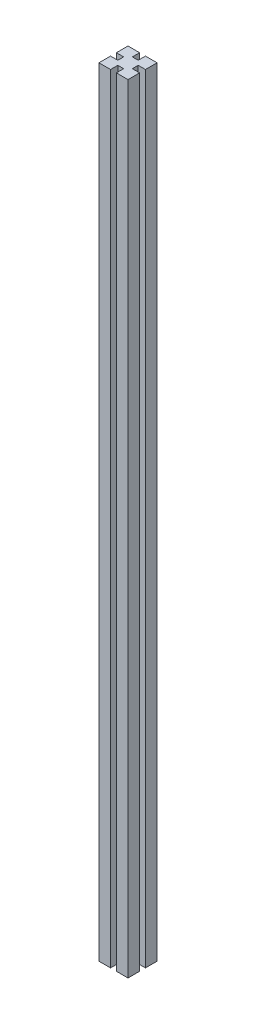
from build123d import *

# Parameters (mm, degrees)
BOSS_EXTRUDE1_DEPTH = 1338
BOSS_EXTRUDE2_DEPTH = 10


with BuildPart() as part:
    # Sketch1 → Boss-Extrude1 (new body)
    with BuildSketch(Plane(origin=(0, 0, 0), x_dir=(1, 0, 0), z_dir=(0, 1, 0))):
        Polygon((-25, 25), (-5, 25), (-5, 12.5), (5, 12.5), (5, 25), (25, 25), (25, 5), (12.5, 5), (12.5, -5), (25, -5), (25, -25), (5, -25), (5, -12.5), (-5, -12.5), (-5, -25), (-25, -25), (-25, -5), (-12.5, -5), (-12.5, 5), (-25, 5), align=None)
    extrude(amount=BOSS_EXTRUDE1_DEPTH)

    # Sketch1_2 → Boss-Extrude2 (add)
    with BuildSketch(Plane(origin=(0, 0, 0), x_dir=(1, 0, 0), z_dir=(0, 1, 0))):
        Polygon((-25, 25), (-5, 25), (-5, 12.5), (5, 12.5), (5, 25), (25, 25), (25, 5), (12.5, 5), (12.5, -5), (25, -5), (25, -25), (5, -25), (5, -12.5), (-5, -12.5), (-5, -25), (-25, -25), (-25, -5), (-12.5, -5), (-12.5, 5), (-25, 5), align=None)
    extrude(amount=BOSS_EXTRUDE2_DEPTH)


solid = part.part
